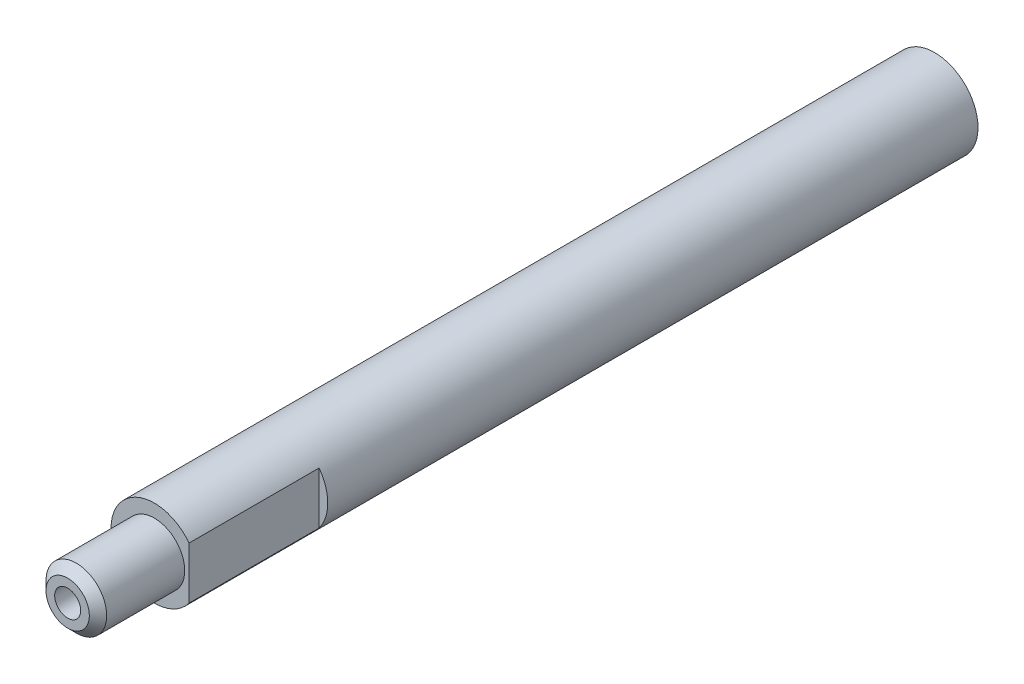
from build123d import *

# Parameters (mm, degrees)
SKETCH1_R          = 5
BASE_EXTRUDE_DEPTH = 100
SKETCH5_OUTSIDE_W  = 32.2
SKETCH5_OUTSIDE_H  = 32.2
SKETCH5_OUTSIDE_R  = 3.5
FRONT_CUT_DEPTH    = 10
SKETCH2_R          = 1.5
FRONT_HOLE_DEPTH   = 10
CHAMFER1_SIZE      = 1
KEYWAY_CUT_DEPTH   = 15
SKETCH4_R          = 2
BACK_HOLE_DEPTH    = 20


with BuildPart() as part:
    # Sketch1 → Base Extrude (new body)
    with BuildSketch(Plane.XY):
        Circle(SKETCH1_R)
    extrude(amount=BASE_EXTRUDE_DEPTH)

    # Sketch5 outside → Front Cut (cut)
    with BuildSketch(Plane.XY.offset(100)):
        Rectangle(SKETCH5_OUTSIDE_W, SKETCH5_OUTSIDE_H)
        Circle(SKETCH5_OUTSIDE_R, mode=Mode.SUBTRACT)
    extrude(amount=-FRONT_CUT_DEPTH, mode=Mode.SUBTRACT)

    # Sketch2 → Front Hole (cut)
    with BuildSketch(Plane.XY.offset(100)):
        Circle(SKETCH2_R)
    extrude(amount=-FRONT_HOLE_DEPTH, mode=Mode.SUBTRACT)

    # Chamfer1
    chamfer1_edges = [part.edges().sort_by_distance(p)[0] for p in [
        (-3.5, 0, 100),
    ]]
    chamfer(chamfer1_edges, length=CHAMFER1_SIZE)

    # Sketch3 → Keyway Cut (cut)
    with BuildSketch(Plane.XY.offset(90)):
        with BuildLine():
            Line((4, 3), (4, -3))
            ThreePointArc((4, -3), (5, 0), (4, 3))
        make_face()
    extrude(amount=-KEYWAY_CUT_DEPTH, mode=Mode.SUBTRACT)

    # Sketch4 → Back Hole (cut)
    with BuildSketch(Plane(origin=(0, 0, 0), x_dir=(-1, 0, 0), z_dir=(0, 0, -1))):
        Circle(SKETCH4_R)
    extrude(amount=-BACK_HOLE_DEPTH, mode=Mode.SUBTRACT)


solid = part.part
